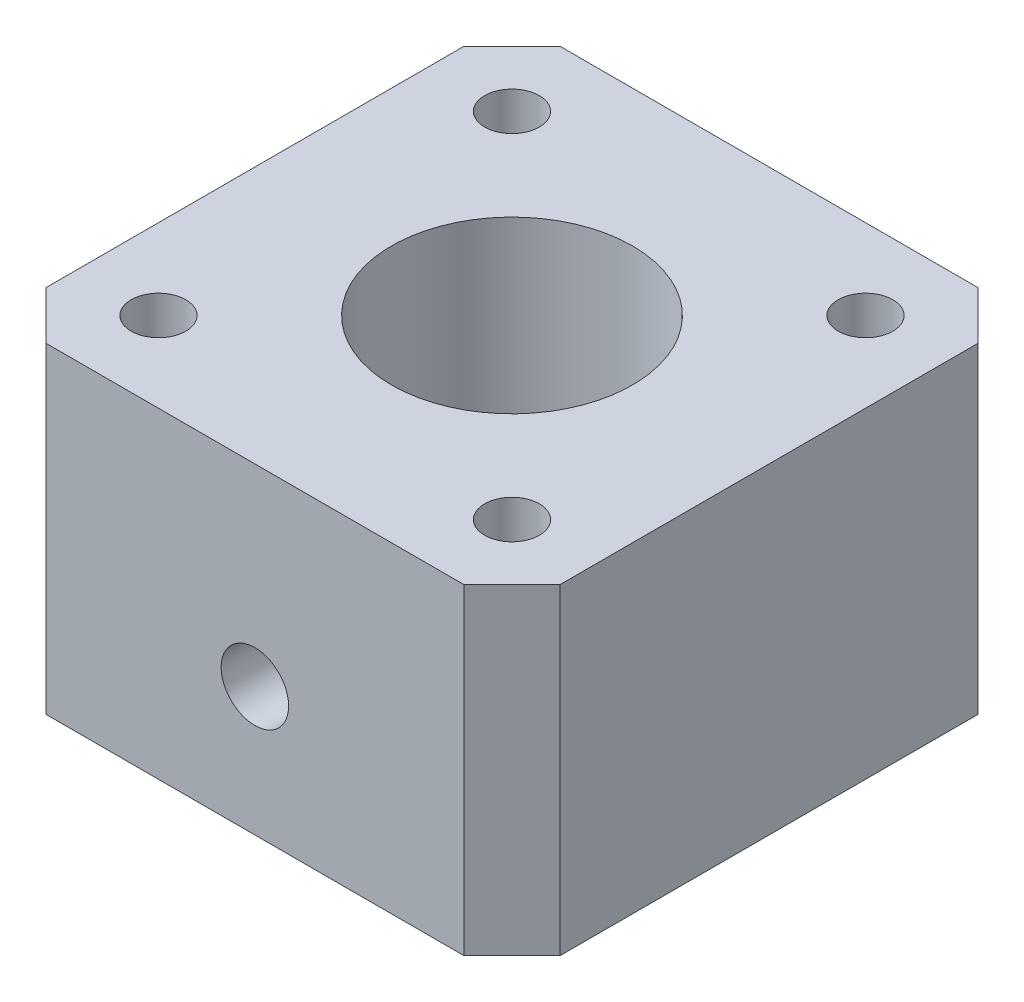
from build123d import *

# Parameters (mm, degrees)
SKETCH1_W                      = 32
SKETCH1_H                      = 32
SKETCH1_R                      = 7.5
BOSS_EXTRUDE1_DEPTH            = 20
CBORE_FOR_M3_SHCS1_D           = 3.4
CBORE_FOR_M3_SHCS1_CBORE_D     = 6.5
CBORE_FOR_M3_SHCS1_CBORE_DEPTH = 3
M5X0_8_TAPPED_HOLE1_REACH      = 42.988
M5X0_8_TAPPED_HOLE1_BORE_R     = 2.1
CHAMFER1_SIZE                  = 3


with BuildPart() as part:
    # Sketch1 → Boss-Extrude1 (new body)
    with BuildSketch(Plane(origin=(0, 0, 0), x_dir=(1, 0, 0), z_dir=(0, 1, 0))):
        Rectangle(SKETCH1_W, SKETCH1_H)
        with Locations(Location((0, 0, 0), (0, 0, 270))):
            Circle(SKETCH1_R, mode=Mode.SUBTRACT)
    extrude(amount=BOSS_EXTRUDE1_DEPTH)

    # CBORE for M3 SHCS1 (through all)
    with Locations(Plane(origin=(0, 0, 0), x_dir=(-1, 0, 0), z_dir=(0, -1, 0))):
        with Locations((-11, -11), (11, -11), (11, 11), (-11, 11)):
            CounterBoreHole(CBORE_FOR_M3_SHCS1_D / 2, CBORE_FOR_M3_SHCS1_CBORE_D / 2, CBORE_FOR_M3_SHCS1_CBORE_DEPTH)

    # M5x0.8 Tapped Hole1 bore → M5x0.8 Tapped Hole1 (cut, up to next)
    with BuildSketch(Plane.XY.offset(16), mode=Mode.PRIVATE) as m5x0_8_tapped_hole1_sk1:
        with Locations((0, 8)):
            Circle(M5X0_8_TAPPED_HOLE1_BORE_R)
    m5x0_8_tapped_hole1_tool1 = extrude(m5x0_8_tapped_hole1_sk1.sketch, amount=-M5X0_8_TAPPED_HOLE1_REACH, mode=Mode.PRIVATE) & part.part
    add(m5x0_8_tapped_hole1_tool1.solids().sort_by_distance((0, 8, 16))[0], mode=Mode.SUBTRACT)

    # Chamfer1
    chamfer1_edges = [part.edges().sort_by_distance(p)[0] for p in [
        (16, 10, 16),
        (-16, 10, 16),
        (-16, 10, -16),
        (16, 10, -16),
    ]]
    chamfer(chamfer1_edges, length=CHAMFER1_SIZE)


solid = part.part
